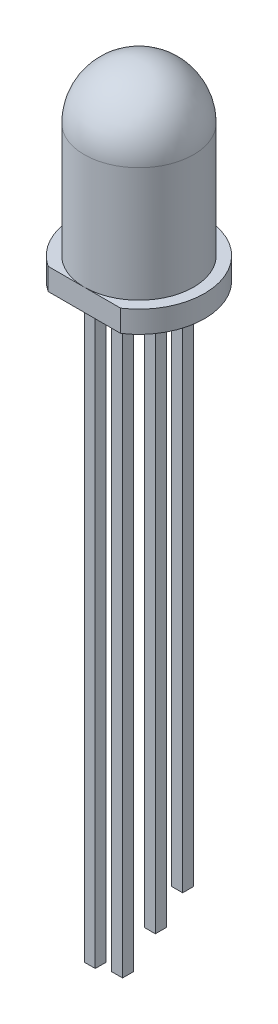
from build123d import *

# Parameters (mm, degrees)
CUT_EXTRUDE2_START      = 10
CUT_EXTRUDE2_DEPTH      = 10
SKETCH3_W               = 0.5
SKETCH3_H               = 0.5
BOSS_EXTRUDE1_DEPTH     = 27
CUT_EXTRUDE3_DEPTH      = 28.331300737
CUT_EXTRUDE3_DEPTH_BACK = 28.331300737
SKETCH5_W               = 0.5
SKETCH5_H               = 1
CUT_EXTRUDE4_DEPTH      = 28.331300737
CUT_EXTRUDE4_DEPTH_BACK = 28.331300737
SKETCH7_W               = 0.5
SKETCH7_H               = 2


with BuildPart() as part:
    # Sketch1 → Revolve1 (revolve)
    with BuildSketch(Plane(origin=(0, 0, 0), x_dir=(0, 0, -1), z_dir=(1, 0, 0))):
        with BuildLine():
            Line((0, 0), (3, 0))
            Line((3, 0), (3, 1))
            Line((3, 1), (2.5, 1))
            Line((2.5, 1), (2.5, 6.25))
            ThreePointArc((2.5, 6.25), (1.767766953, 8.017766953), (0, 8.75))
            Line((0, 8.75), (0, 0))
        make_face()
    revolve(axis=Axis((0, 8.75, 0), (0, -1, 0)))

    # Sketch2 → Cut-Extrude2 (cut)
    with BuildSketch(Plane(origin=(0, 0, 0), x_dir=(1, 0, 0), z_dir=(0, 1, 0)).offset(CUT_EXTRUDE2_START)):
        with BuildLine():
            Line((-1.658312395, -2.5), (1.658312395, -2.5))
            ThreePointArc((1.658312395, -2.5), (0, -3), (-1.658312395, -2.5))
        make_face()
    extrude(amount=-CUT_EXTRUDE2_DEPTH, mode=Mode.SUBTRACT)

    # Sketch3 → Boss-Extrude1 (add)
    with BuildSketch(Plane.XZ):
        with Locations((0, 2)):
            Rectangle(SKETCH3_W, SKETCH3_H)
        with Locations((0, 0.75)):
            Rectangle(SKETCH3_W, SKETCH3_H)
        with Locations((0, -0.75)):
            Rectangle(SKETCH3_W, SKETCH3_H)
        with Locations((0, -2)):
            Rectangle(SKETCH3_W, SKETCH3_H)
    extrude(amount=BOSS_EXTRUDE1_DEPTH)

    # Sketch5 → Cut-Extrude3 (cut, two sides: drawn at the far end of the back side and taken through both)
    with BuildSketch(Plane(origin=(0, 0, 0), x_dir=(0, 0, -1), z_dir=(1, 0, 0)).offset(-CUT_EXTRUDE3_DEPTH_BACK)):
        with Locations((-2, -26.5)):
            Rectangle(SKETCH5_W, SKETCH5_H)
        with Locations((0.75, -26.5)):
            Rectangle(SKETCH5_W, SKETCH5_H)
    extrude(amount=CUT_EXTRUDE3_DEPTH + CUT_EXTRUDE3_DEPTH_BACK, mode=Mode.SUBTRACT)

    # Sketch7 → Cut-Extrude4 (cut, two sides: drawn at the far end of the back side and taken through both)
    with BuildSketch(Plane(origin=(0, 0, 0), x_dir=(0, 0, -1), z_dir=(1, 0, 0)).offset(-CUT_EXTRUDE4_DEPTH_BACK)):
        with Locations((2, -26)):
            Rectangle(SKETCH7_W, SKETCH7_H)
    extrude(amount=CUT_EXTRUDE4_DEPTH + CUT_EXTRUDE4_DEPTH_BACK, mode=Mode.SUBTRACT)


solid = part.part
